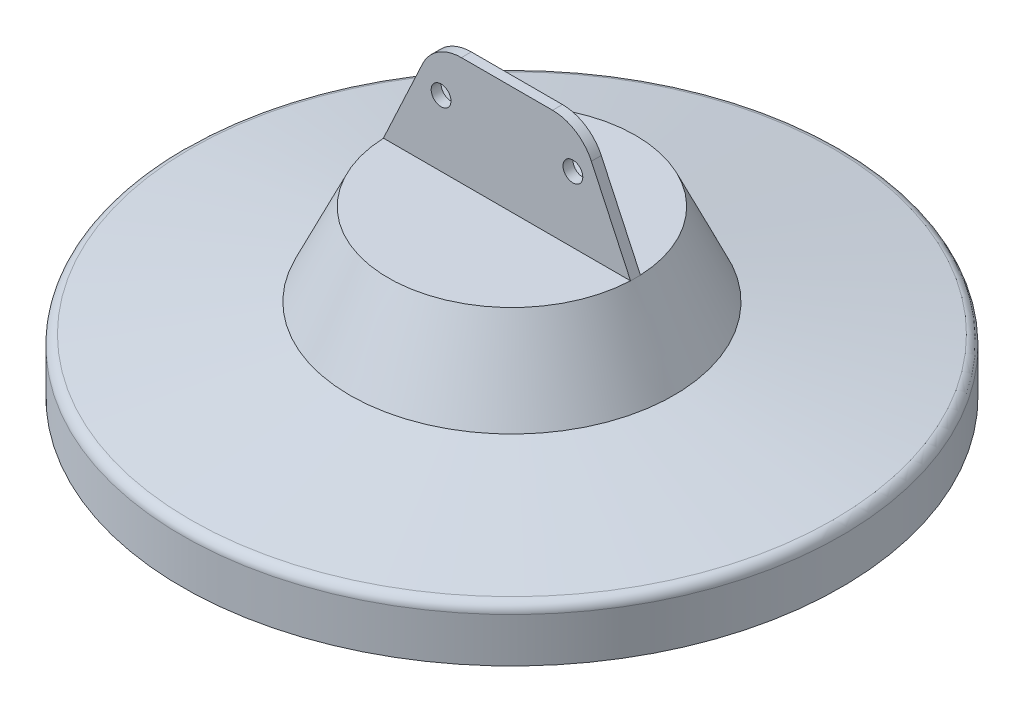
from build123d import *

# Parameters (mm, degrees)
SKETCH2_R           = 3
BOSS_EXTRUDE1_DEPTH = 1.5


with BuildPart() as part:
    # Sketch1 → Revolve1 (revolve)
    with BuildSketch(Plane.XY, mode=Mode.PRIVATE) as revolve1_sk:
        with BuildLine():
            Line((0, 0), (-100, 0))
            Line((-100, 0), (-100, 13.517830348))
            ThreePointArc((-100, 13.517830348), (-99.298133329, 15.446193177), (-97.520944533, 16.472253607))
            Line((-97.520944533, 16.472253607), (-49.157691454, 25))
            Line((-49.157691454, 25), (-37.5, 50))
            Line((-37.5, 50), (0, 50))
            Line((0, 50), (0, 0))
        make_face()
    revolve(revolve1_sk.sketch.rotate(Axis((0, 0, 0), (0, 1, 0)), 270), axis=Axis((0, 0, 0), (0, 1, 0)))  # turned: the seam where the file's is

    # Sketch2 → Boss-Extrude1 (add, symmetric)
    with BuildSketch(Plane.XY):
        with BuildLine():
            Line((-37.5, 50), (-25.611935122, 75.494037403))
            ThreePointArc((-25.611935122, 75.494037403), (-20.814828799, 80.964088796), (-13.82993389, 83))
            Line((-13.82993389, 83), (13.82993389, 83))
            ThreePointArc((13.82993389, 83), (20.814828799, 80.964088796), (25.611935122, 75.494037403))
            Line((25.611935122, 75.494037403), (37.5, 50))
            Line((37.5, 50), (-37.5, 50))
        make_face()
        with Locations((-20, 70)):
            Circle(SKETCH2_R, mode=Mode.SUBTRACT)
        with Locations((20, 70)):
            Circle(SKETCH2_R, mode=Mode.SUBTRACT)
    extrude(amount=BOSS_EXTRUDE1_DEPTH, both=True)


solid = part.part
